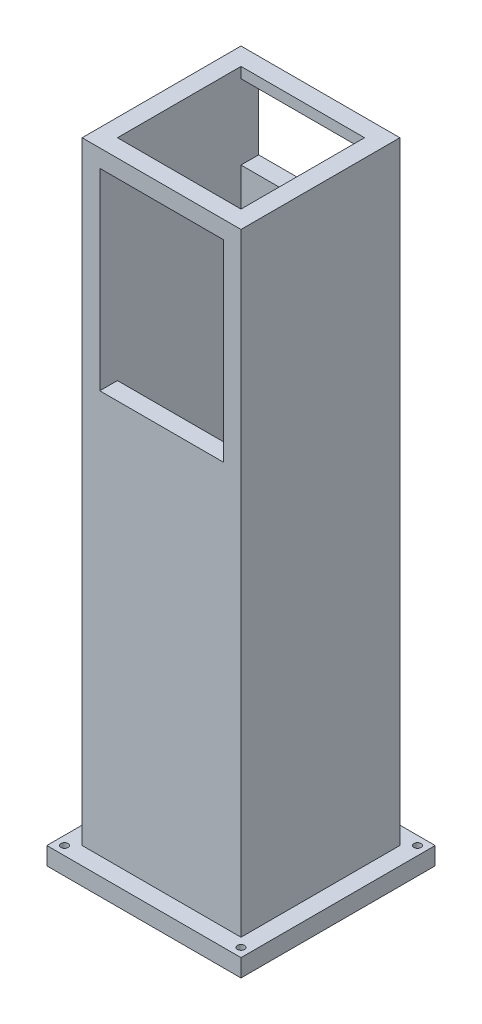
from build123d import *

# Parameters (mm, degrees)
CROQUIS1_W                 = 45
CROQUIS1_H                 = 45
SALIENTE_EXTRUIR1_DEPTH    = 300
CROQUIS4_W                 = 18
CROQUIS4_H                 = 34
CORTAR_EXTRUIR2_DEPTH      = 46
CROQUIS8_W                 = 35
CROQUIS8_H                 = 35
CORTAR_EXTRUIR3_DEPTH      = 301
CROQUIS9_W                 = 35
CROQUIS9_H                 = 21.174410022
CORTAR_EXTRUIR4_DEPTH      = 10
CROQUIS10_R                = 1
CORTAR_EXTRUIR5_DEPTH      = 10
CROQUIS17_W                = 35
CROQUIS17_H                = 54.573397986
CORTAR_EXTRUIR9_DEPTH      = 10
CROQUIS11_W                = 45
CROQUIS11_H                = 26.387879272
CORTAR_EXTRUIR6_DEPTH      = 46
CROQUIS13_W                = 45
CROQUIS13_H                = 100
CORTAR_EXTRUIR7_DEPTH      = 23.5
CORTAR_EXTRUIR7_DEPTH_BACK = 23.5
CROQUIS14_W                = 55
CROQUIS14_H                = 55
SALIENTE_EXTRUIR2_DEPTH    = 5
CROQUIS16_R                = 1
CORTAR_EXTRUIR8_DEPTH      = 1
CORTAR_EXTRUIR8_DEPTH_BACK = 179.612120728


with BuildPart() as part:
    # Croquis1 → Saliente-Extruir1 (new body)
    with BuildSketch(Plane(origin=(0, 0, 0), x_dir=(1, 0, 0), z_dir=(0, 1, 0))):
        Rectangle(CROQUIS1_W, CROQUIS1_H)
    extrude(amount=SALIENTE_EXTRUIR1_DEPTH)

    # Croquis4 → Cortar-Extruir2 (cut, through all)
    with BuildSketch(Plane.ZY.offset(22.5)):
        with Locations((13.5, 17)):
            Rectangle(CROQUIS4_W, CROQUIS4_H)
    extrude(amount=-CORTAR_EXTRUIR2_DEPTH, mode=Mode.SUBTRACT)

    # Croquis8 → Cortar-Extruir3 (cut, through all)
    with BuildSketch(Plane(origin=(0, 300, 0), x_dir=(1, 0, 0), z_dir=(0, 1, 0))):
        Rectangle(CROQUIS8_W, CROQUIS8_H)
    extrude(amount=-CORTAR_EXTRUIR3_DEPTH, mode=Mode.SUBTRACT)

    # Croquis9 → Cortar-Extruir4 (cut)
    with BuildSketch(Plane(origin=(0, 0, -22.5), x_dir=(-1, 0, 0), z_dir=(0, 0, -1))):
        with Locations((0, 260)):
            Rectangle(CROQUIS9_W, CROQUIS9_H)
    extrude(amount=-CORTAR_EXTRUIR4_DEPTH, mode=Mode.SUBTRACT)

    # Croquis10 → Cortar-Extruir5 (cut)
    with BuildSketch(Plane.XY.offset(22.5)):
        with Locations((0, 260)):
            Circle(CROQUIS10_R)
    extrude(amount=-CORTAR_EXTRUIR5_DEPTH, mode=Mode.SUBTRACT)

    # Croquis17 → Cortar-Extruir9 (cut)
    with BuildSketch(Plane.XY.offset(22.5)):
        with Locations((0, 241.325421735)):
            Rectangle(CROQUIS17_W, CROQUIS17_H)
    extrude(amount=-CORTAR_EXTRUIR9_DEPTH, mode=Mode.SUBTRACT)

    # Croquis11 → Cortar-Extruir6 (cut, through all)
    with BuildSketch(Plane.XY.offset(22.5)):
        with Locations((0, 286.806060364)):
            Rectangle(CROQUIS11_W, CROQUIS11_H)
    extrude(amount=-CORTAR_EXTRUIR6_DEPTH, mode=Mode.SUBTRACT)

    # Croquis13 → Cortar-Extruir7 (cut, two sides)
    with BuildSketch(Plane(origin=(0, 0, 0), x_dir=(0, 0, -1), z_dir=(1, 0, 0))) as cortar_extruir7_sk:
        with Locations((0, 50)):
            Rectangle(CROQUIS13_W, CROQUIS13_H)
    extrude(amount=CORTAR_EXTRUIR7_DEPTH, mode=Mode.SUBTRACT)
    extrude(cortar_extruir7_sk.sketch, amount=-CORTAR_EXTRUIR7_DEPTH_BACK, mode=Mode.SUBTRACT)

    # Croquis14 → Saliente-Extruir2 (add)
    with BuildSketch(Plane.XZ.offset(-100)):
        Rectangle(CROQUIS14_W, CROQUIS14_H)
    extrude(amount=SALIENTE_EXTRUIR2_DEPTH)

    # Croquis16 → Cortar-Extruir8 (cut, two sides)
    with BuildSketch(Plane.XZ.offset(-95)) as cortar_extruir8_sk:
        with Locations((25, 25)):
            Circle(CROQUIS16_R)
        with Locations((-25, 25)):
            Circle(CROQUIS16_R)
        with Locations((-25, -25)):
            Circle(CROQUIS16_R)
        with Locations((25, -25)):
            Circle(CROQUIS16_R)
    extrude(amount=CORTAR_EXTRUIR8_DEPTH, mode=Mode.SUBTRACT)
    extrude(cortar_extruir8_sk.sketch, amount=-CORTAR_EXTRUIR8_DEPTH_BACK, mode=Mode.SUBTRACT)


solid = part.part
